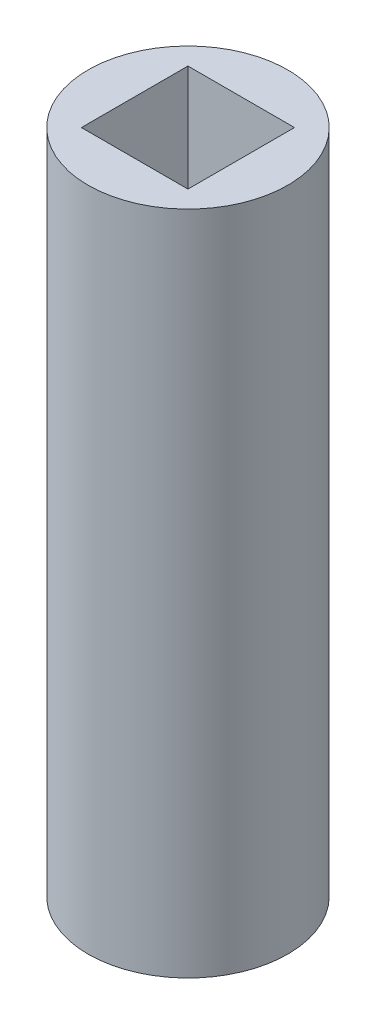
from build123d import *

# Parameters (mm, degrees)
ESQUISSE1_R        = 3
ESQUISSE1_W        = 3.2
ESQUISSE1_H        = 3.2
BOSS_EXTRU_1_DEPTH = 20


with BuildPart() as part:
    # Esquisse1 → Boss.-Extru.1 (new body)
    with BuildSketch(Plane(origin=(0, 0, 0), x_dir=(1, 0, 0), z_dir=(0, 1, 0))):
        Circle(ESQUISSE1_R)
        Rectangle(ESQUISSE1_W, ESQUISSE1_H, mode=Mode.SUBTRACT)
    extrude(amount=BOSS_EXTRU_1_DEPTH)


solid = part.part
